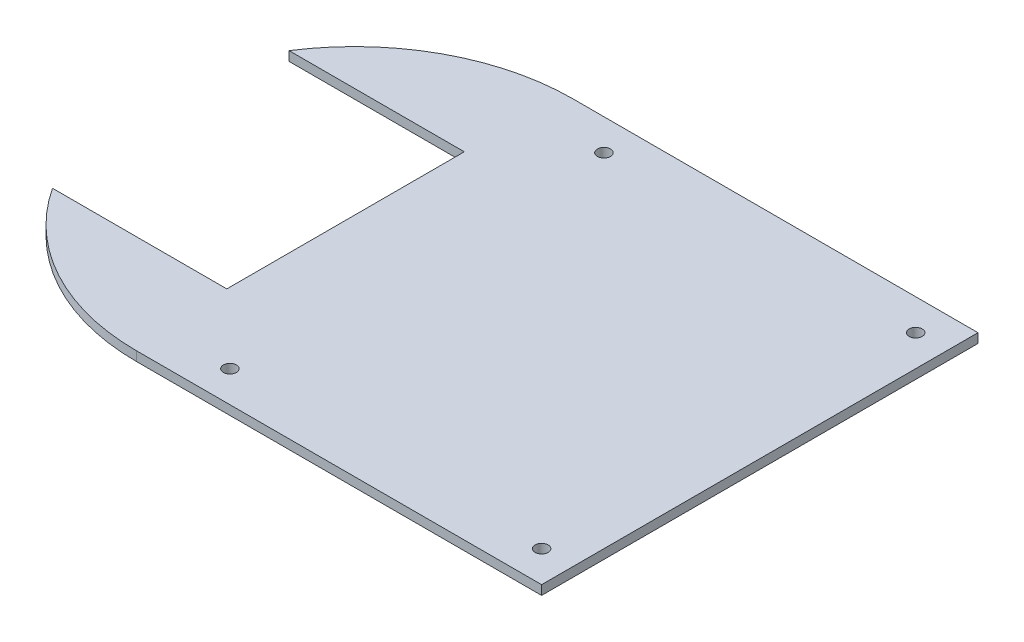
from build123d import *

# Parameters (mm, degrees)
SKETCH1_R           = 2.1
BOSS_EXTRUDE1_DEPTH = 3


with BuildPart() as part:
    # Sketch1 → Boss-Extrude1 (new body)
    with BuildSketch(Plane(origin=(0, 0, 0), x_dir=(1, 0, 0), z_dir=(0, 1, 0))):
        with BuildLine():
            Line((65, -70), (-65, -70))
            ThreePointArc((-65, -70), (-98.297426292, -61.573382255), (-123.578147349, -38.32232578))
            Line((-123.578147349, -38.32232578), (-67.663660863, -38.32232578))
            Line((-67.663660863, -38.32232578), (-67.663660863, 37.858201233))
            Line((-67.663660863, 37.858201233), (-123.879169486, 37.858201233))
            ThreePointArc((-123.879169486, 37.858201233), (-98.540467451, 61.441330089), (-65, 70))
            Line((-65, 70), (65, 70))
            Line((65, 70), (65, -70))
        make_face()
        with Locations((-44.999784569, 59.999822317)):
            Circle(SKETCH1_R, mode=Mode.SUBTRACT)
        with Locations((-44.999784569, -60.000177683)):
            Circle(SKETCH1_R, mode=Mode.SUBTRACT)
        with Locations((55.000215431, 59.999822317)):
            Circle(SKETCH1_R, mode=Mode.SUBTRACT)
        with Locations((55.000215431, -60.000177683)):
            Circle(SKETCH1_R, mode=Mode.SUBTRACT)
    extrude(amount=BOSS_EXTRUDE1_DEPTH)


solid = part.part
